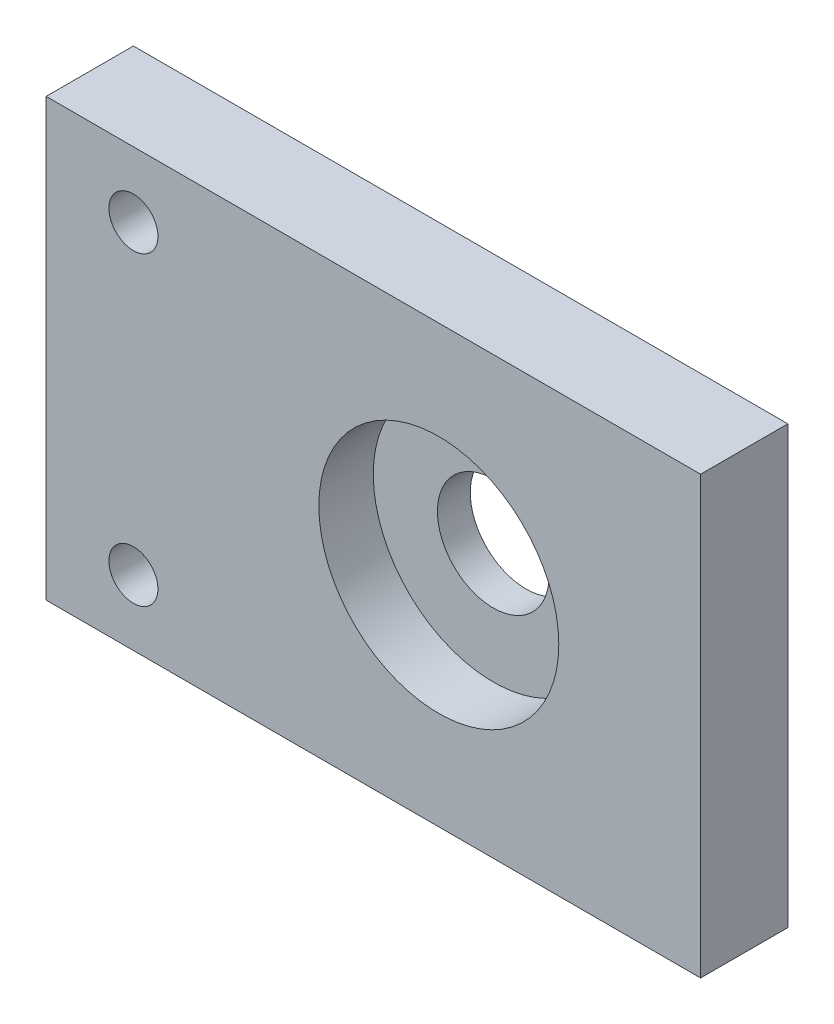
from build123d import *

# Parameters (mm, degrees)
SKETCH1_W                                        = 95.25
SKETCH1_H                                        = 63.5
BOSS_EXTRUDE1_DEPTH                              = 12.7
CBORE_FOR_1_4_SOCKET_HEAD_CAP_SCREW1_D           = 7.14248
CBORE_FOR_1_4_SOCKET_HEAD_CAP_SCREW1_CBORE_D     = 11.1125
CBORE_FOR_1_4_SOCKET_HEAD_CAP_SCREW1_CBORE_DEPTH = 6.35
CBORE_FOR_5_8_SOCKET_HEAD_CAP_SCREW1_D           = 16.256
CBORE_FOR_5_8_SOCKET_HEAD_CAP_SCREW1_CBORE_D     = 34.925
CBORE_FOR_5_8_SOCKET_HEAD_CAP_SCREW1_CBORE_DEPTH = 7.9248


with BuildPart() as part:
    # Sketch1 → Boss-Extrude1 (new body)
    with BuildSketch(Plane.XY):
        with Locations((47.625, 31.75)):
            Rectangle(SKETCH1_W, SKETCH1_H)
    extrude(amount=BOSS_EXTRUDE1_DEPTH)

    # CBORE for 1/4 Socket Head Cap Screw1 (through all)
    with Locations(Plane(origin=(0, 0, 0), x_dir=(-1, 0, 0), z_dir=(0, 0, -1))):
        with Locations((-12.7, 53.975), (-12.7, 9.525)):
            CounterBoreHole(CBORE_FOR_1_4_SOCKET_HEAD_CAP_SCREW1_D / 2, CBORE_FOR_1_4_SOCKET_HEAD_CAP_SCREW1_CBORE_D / 2, CBORE_FOR_1_4_SOCKET_HEAD_CAP_SCREW1_CBORE_DEPTH)

    # CBORE for 5/8 Socket Head Cap Screw1 (through all)
    with Locations(Plane.XY.offset(12.7)):
        with Locations((57.15, 31.75)):
            CounterBoreHole(CBORE_FOR_5_8_SOCKET_HEAD_CAP_SCREW1_D / 2, CBORE_FOR_5_8_SOCKET_HEAD_CAP_SCREW1_CBORE_D / 2, CBORE_FOR_5_8_SOCKET_HEAD_CAP_SCREW1_CBORE_DEPTH)


solid = part.part
